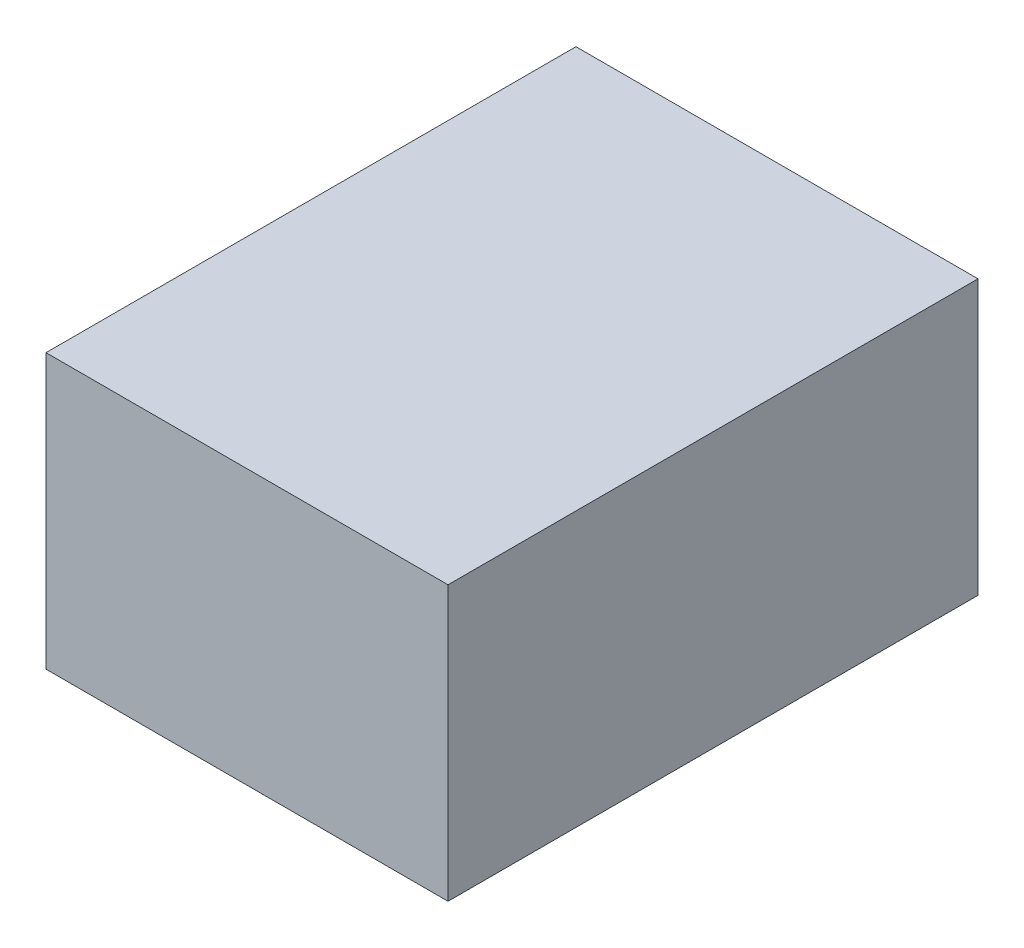
from build123d import *

# Parameters (mm, degrees)
SKETCH1_W           = 22
SKETCH1_H           = 29
BOSS_EXTRUDE1_DEPTH = 15


with BuildPart() as part:
    # Sketch1 → Boss-Extrude1 (new body)
    with BuildSketch(Plane(origin=(0, 0, 0), x_dir=(1, 0, 0), z_dir=(0, 1, 0))):
        Rectangle(SKETCH1_W, SKETCH1_H)
    extrude(amount=BOSS_EXTRUDE1_DEPTH)


solid = part.part
